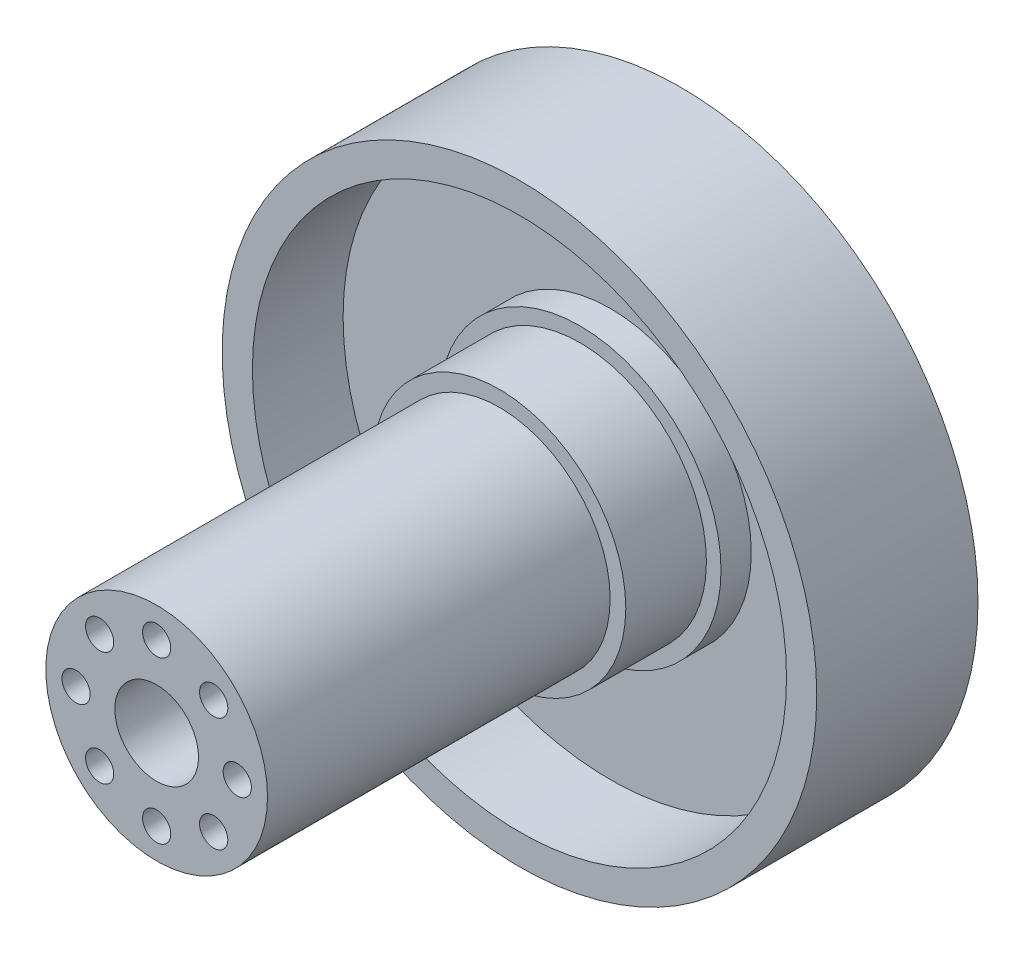
from build123d import *

# Parameters (mm, degrees)
SKETCH2_R           = 29.5
BOSS_EXTRUDE1_DEPTH = 7
SKETCH3_R           = 14
BOSS_EXTRUDE2_DEPTH = 3
SKETCH5_R           = 12.55
BOSS_EXTRUDE3_DEPTH = 8
SKETCH6_R           = 11
BOSS_EXTRUDE4_DEPTH = 34
SKETCH7_R           = 2.1
CUT_EXTRUDE1_DEPTH  = 33.8
SKETCH8_R           = 1.4
CUT_EXTRUDE2_DEPTH  = 19.2
SKETCH9_R           = 4.15
CUT_EXTRUDE3_DEPTH  = 9
SKETCH10_R          = 2.07
CUT_EXTRUDE4_DEPTH  = 5
SKETCH11_R          = 29.5
SKETCH11_R_2        = 26.5
BOSS_EXTRUDE5_DEPTH = 9


with BuildPart() as part:
    # Sketch2 → Boss-Extrude1 (new body)
    with BuildSketch(Plane.XY):
        Circle(SKETCH2_R)
    extrude(amount=BOSS_EXTRUDE1_DEPTH)

    # Sketch3 → Boss-Extrude2 (add)
    with BuildSketch(Plane.XY.offset(7)):
        Circle(SKETCH3_R)
    extrude(amount=BOSS_EXTRUDE2_DEPTH)

    # Sketch5 → Boss-Extrude3 (add)
    with BuildSketch(Plane.XY.offset(10)):
        Circle(SKETCH5_R)
    extrude(amount=BOSS_EXTRUDE3_DEPTH)

    # Sketch6 → Boss-Extrude4 (add)
    with BuildSketch(Plane.XY.offset(18)):
        Circle(SKETCH6_R)
    extrude(amount=BOSS_EXTRUDE4_DEPTH)

    # Sketch7 → Cut-Extrude1 (cut)
    with BuildSketch(Plane(origin=(0, 0, 0), x_dir=(-1, 0, 0), z_dir=(0, 0, -1))):
        with Locations((8, 0)):
            Circle(SKETCH7_R)
        with Locations((5.656854249, -5.656854249)):
            Circle(SKETCH7_R)
        with Locations((0, -8)):
            Circle(SKETCH7_R)
        with Locations((-5.656854249, -5.656854249)):
            Circle(SKETCH7_R)
        with Locations((-8, 0)):
            Circle(SKETCH7_R)
        with Locations((-5.656854249, 5.656854249)):
            Circle(SKETCH7_R)
        with Locations((0, 8)):
            Circle(SKETCH7_R)
        with Locations((5.656854249, 5.656854249)):
            Circle(SKETCH7_R)
    extrude(amount=-CUT_EXTRUDE1_DEPTH, mode=Mode.SUBTRACT)

    # Sketch8 → Cut-Extrude2 (cut, through all)
    with BuildSketch(Plane(origin=(0, 0, 33.8), x_dir=(-1, 0, 0), z_dir=(0, 0, -1))):
        with Locations((-8, 0)):
            Circle(SKETCH8_R)
        with Locations((-5.656854249, 5.656854249)):
            Circle(SKETCH8_R)
        with Locations((0, 8)):
            Circle(SKETCH8_R)
        with Locations((5.656854249, 5.656854249)):
            Circle(SKETCH8_R)
        with Locations((8, 0)):
            Circle(SKETCH8_R)
        with Locations((5.656854249, -5.656854249)):
            Circle(SKETCH8_R)
        with Locations((0, -8)):
            Circle(SKETCH8_R)
        with Locations((-5.656854249, -5.656854249)):
            Circle(SKETCH8_R)
    extrude(amount=-CUT_EXTRUDE2_DEPTH, mode=Mode.SUBTRACT)

    # Sketch9 → Cut-Extrude3 (cut)
    with BuildSketch(Plane.XY.offset(52)):
        Circle(SKETCH9_R)
    extrude(amount=-CUT_EXTRUDE3_DEPTH, mode=Mode.SUBTRACT)

    # Sketch10 → Cut-Extrude4 (cut)
    with BuildSketch(Plane.XY):
        with Locations((-26, 0)):
            Circle(SKETCH10_R)
        with Locations((0, 26)):
            Circle(SKETCH10_R)
        with Locations((26, 0)):
            Circle(SKETCH10_R)
        with Locations((0, -26)):
            Circle(SKETCH10_R)
    extrude(amount=CUT_EXTRUDE4_DEPTH, mode=Mode.SUBTRACT)

    # Sketch11 → Boss-Extrude5 (add)
    with BuildSketch(Plane.XY.offset(7)):
        Circle(SKETCH11_R)
        Circle(SKETCH11_R_2, mode=Mode.SUBTRACT)
    extrude(amount=BOSS_EXTRUDE5_DEPTH)


solid = part.part
